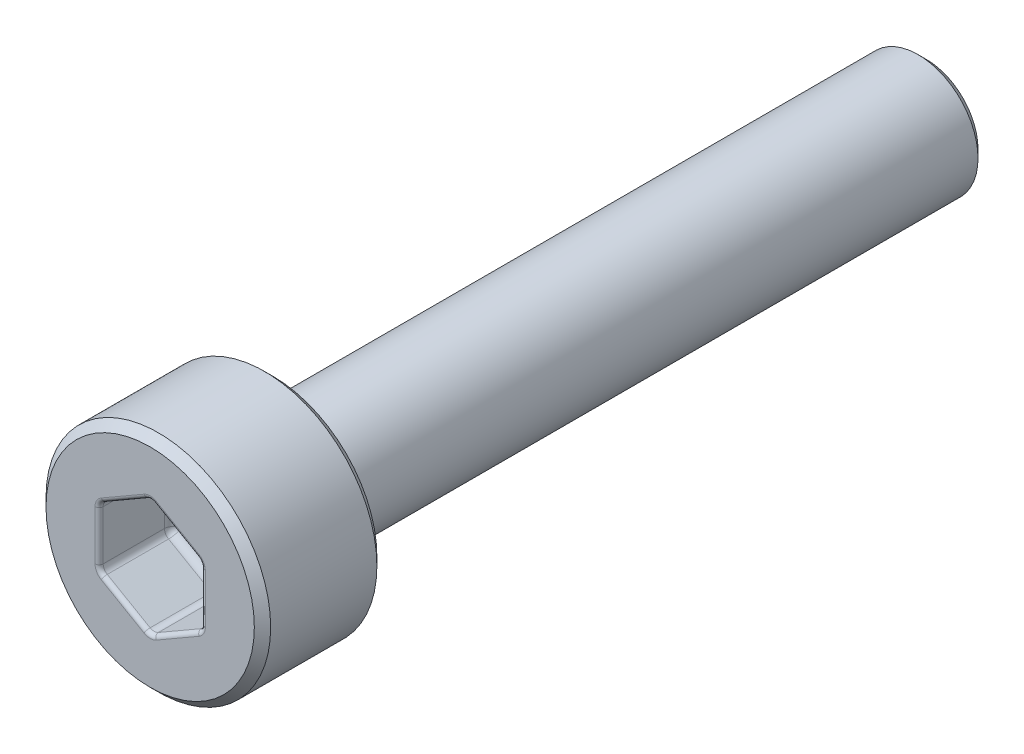
from build123d import *

# Parameters (mm, degrees)
SCHNITT_LINEAR_AUSTRAGEN1_DEPTH = 1.8
FASE1_SIZE                      = 0.2
VERRUNDUNG1_R                   = 0.2
VERRUNDUNG2_R                   = 0.1


with BuildPart() as part:
    # Skizze1 → Rotation1 (revolve)
    with BuildSketch(Plane(origin=(0, 0, 0), x_dir=(0, 0, -1), z_dir=(1, 0, 0))):
        Polygon((-3, 0), (-3, 2.75), (0, 2.75), (0, 1.465), (16, 1.465), (16, 0), align=None)
    revolve(axis=Axis((0, 0, 21.919879518), (0, 0, -1)))

    # Skizze2 → Schnitt-Linear austragen1 (cut)
    with BuildSketch(Plane.XY.offset(3)):
        Polygon((1.25, -0.721687836), (1.25, 0.721687836), (0, 1.443375673), (-1.25, 0.721687836), (-1.25, -0.721687836), (0, -1.443375673), align=None)
    extrude(amount=-SCHNITT_LINEAR_AUSTRAGEN1_DEPTH, mode=Mode.SUBTRACT)

    # Fase1
    fase1_edges = [part.edges().sort_by_distance(p)[0] for p in [
        (0, -1.465, -16),
        (0, -2.75, 0),
        (0, -2.75, 3),
    ]]
    chamfer(fase1_edges, length=FASE1_SIZE)

    # Verrundung1
    verrundung1_edges = [part.edges().sort_by_distance(p)[0] for p in [
        (0.625, -1.082531755, 1.2),
        (1.25, -0.721687836, 2.1),
        (-0.625, -1.082531755, 1.2),
        (0, -1.443375673, 2.1),
        (-1.25, 0, 1.2),
        (-1.25, -0.721687836, 2.1),
        (-0.625, 1.082531755, 1.2),
        (-1.25, 0.721687836, 2.1),
        (0.625, 1.082531755, 1.2),
        (0, 1.443375673, 2.1),
        (1.25, 0, 1.2),
        (1.25, 0.721687836, 2.1),
        (0, -1.465, 0),
    ]]
    fillet(verrundung1_edges, radius=VERRUNDUNG1_R)

    # Verrundung2
    verrundung2_edges = [part.edges().sort_by_distance(p)[0] for p in [
        (-0.625, -1.082531755, 3),
        (-1.25, 0, 3),
        (-0.625, 1.082531755, 3),
        (0.625, 1.082531755, 3),
        (1.25, 0, 3),
        (0.625, -1.082531755, 3),
        (-1.223205081, -0.706217783, 3),
        (0, -1.412435565, 3),
        (1.223205081, -0.706217783, 3),
        (1.223205081, 0.706217783, 3),
        (0, 1.412435565, 3),
        (-1.223205081, 0.706217783, 3),
    ]]
    fillet(verrundung2_edges, radius=VERRUNDUNG2_R)


solid = part.part
